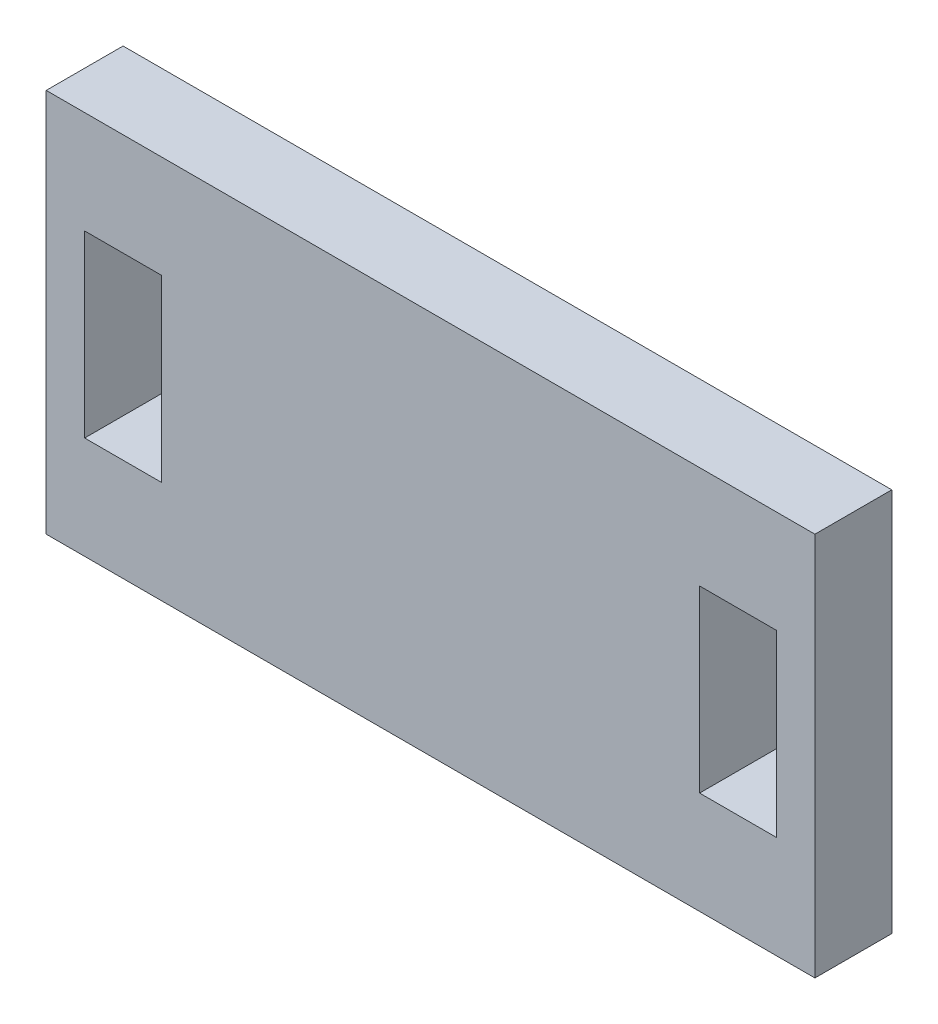
from build123d import *

# Parameters (mm, degrees)
SKETCH1_W           = 30
SKETCH1_H           = 15
SKETCH1_W_2         = 3
SKETCH1_H_2         = 7
BOSS_EXTRUDE1_DEPTH = 1.5


with BuildPart() as part:
    # Sketch1 → Boss-Extrude1 (new body, symmetric)
    with BuildSketch(Plane.XY):
        Rectangle(SKETCH1_W, SKETCH1_H)
        with Locations((-12, 0)):
            Rectangle(SKETCH1_W_2, SKETCH1_H_2, mode=Mode.SUBTRACT)
        with Locations((12, 0)):
            Rectangle(SKETCH1_W_2, SKETCH1_H_2, mode=Mode.SUBTRACT)
    extrude(amount=BOSS_EXTRUDE1_DEPTH, both=True)


solid = part.part
